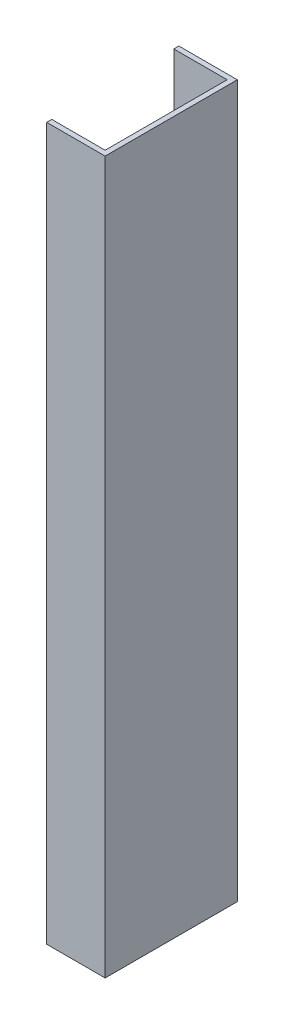
from build123d import *

# Parameters (mm, degrees)
SALIENTE_EXTRUIR1_DEPTH = 222.25


with BuildPart() as part:
    # Croquis1 → Saliente-Extruir1 (new body, symmetric)
    with BuildSketch(Plane(origin=(0, 0, 0), x_dir=(1, 0, 0), z_dir=(0, 1, 0))):
        Polygon((0, 41.275), (0, -41.275), (-36.5125, -41.275), (-36.5125, -38.1), (-3.175, -38.1), (-3.175, 38.1), (-36.5125, 38.1), (-36.5125, 41.275), align=None)
    extrude(amount=SALIENTE_EXTRUIR1_DEPTH, both=True)


solid = part.part
